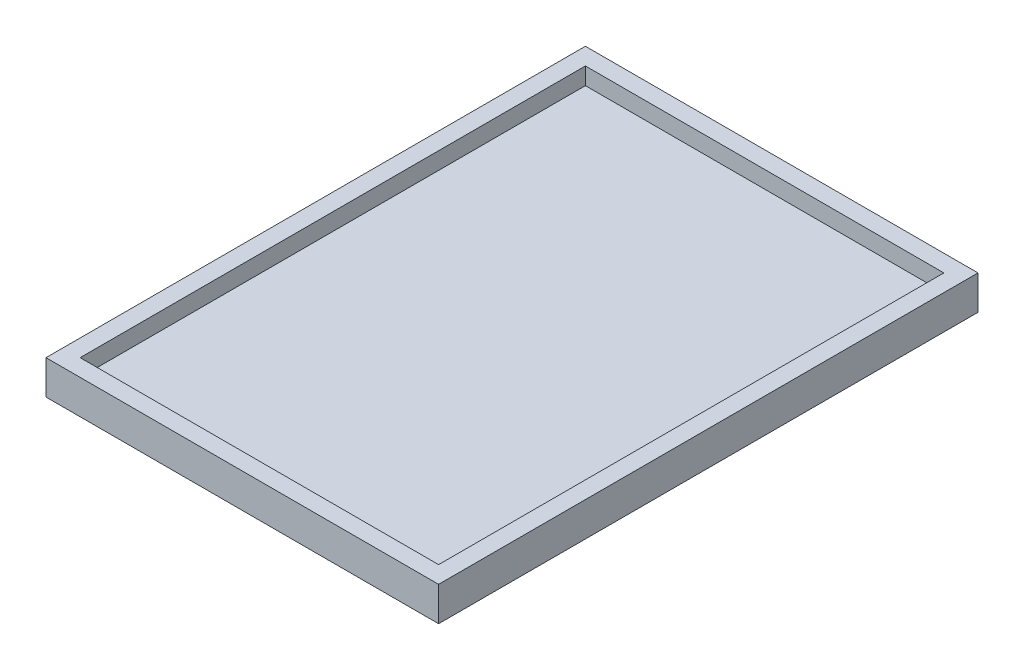
from build123d import *

# Parameters (mm, degrees)
CROQUIS1_W              = 115
CROQUIS1_H              = 158
SALIENTE_EXTRUIR1_DEPTH = 10
CROQUIS2_W              = 105
CROQUIS2_H              = 148
CORTAR_EXTRUIR2_DEPTH   = 5


with BuildPart() as part:
    # Croquis1 → Saliente-Extruir1 (new body)
    with BuildSketch(Plane(origin=(0, 0, 0), x_dir=(1, 0, 0), z_dir=(0, 1, 0))):
        with Locations((57.5, 79)):
            Rectangle(CROQUIS1_W, CROQUIS1_H)
    extrude(amount=SALIENTE_EXTRUIR1_DEPTH)

    # Croquis2 → Cortar-Extruir2 (cut)
    with BuildSketch(Plane(origin=(0, 10, 0), x_dir=(1, 0, 0), z_dir=(0, 1, 0))):
        with Locations((57.5, 79)):
            Rectangle(CROQUIS2_W, CROQUIS2_H)
    extrude(amount=-CORTAR_EXTRUIR2_DEPTH, mode=Mode.SUBTRACT)


solid = part.part
